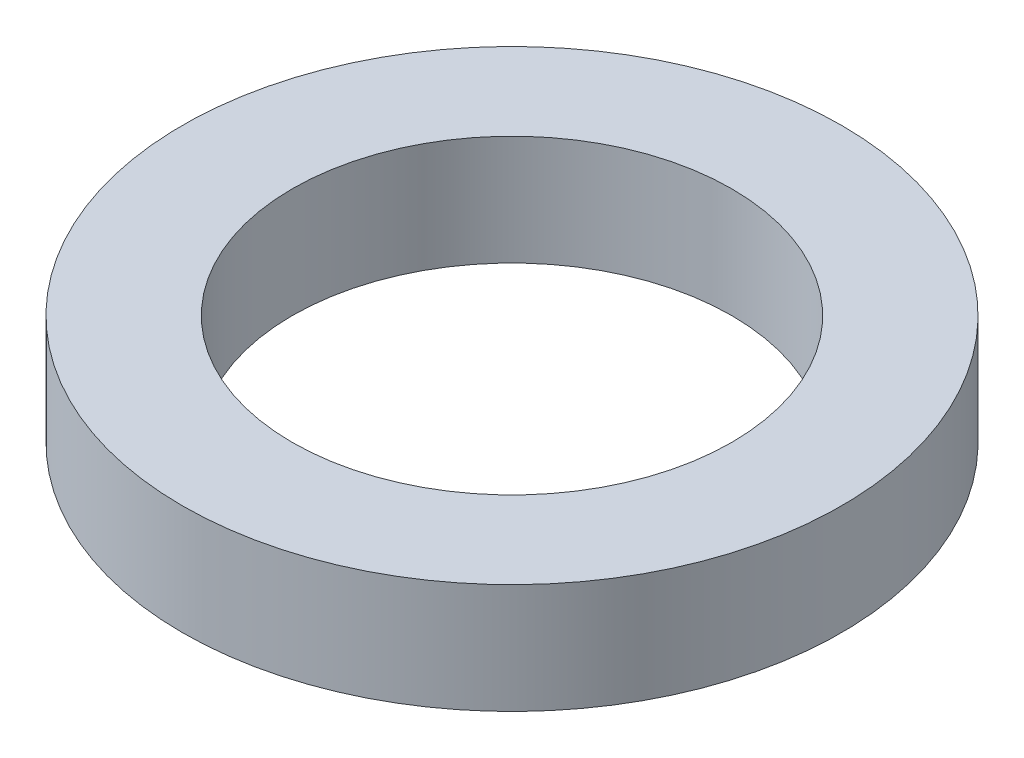
from build123d import *

# Parameters (mm, degrees)
SKETCH1_R           = 1.5
SKETCH1_R_2         = 1
BOSS_EXTRUDE1_DEPTH = 0.5


with BuildPart() as part:
    # Sketch1 → Boss-Extrude1 (new body)
    with BuildSketch(Plane(origin=(0, 0, 0), x_dir=(1, 0, 0), z_dir=(0, 1, 0))):
        Circle(SKETCH1_R)
        Circle(SKETCH1_R_2, mode=Mode.SUBTRACT)
    extrude(amount=BOSS_EXTRUDE1_DEPTH)


solid = part.part
